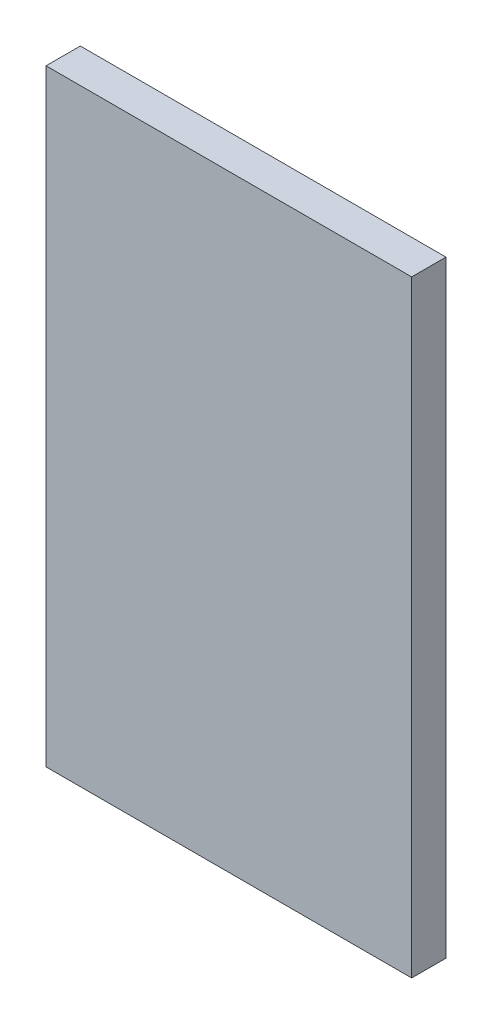
from build123d import *

# Parameters (mm, degrees)
SKETCH1_W           = 27.1
SKETCH1_H           = 45
BOSS_EXTRUDE1_DEPTH = 2.54


with BuildPart() as part:
    # Sketch1 → Boss-Extrude1 (new body)
    with BuildSketch(Plane.XY):
        with Locations((13.55, 22.5)):
            Rectangle(SKETCH1_W, SKETCH1_H)
    extrude(amount=BOSS_EXTRUDE1_DEPTH)


solid = part.part
